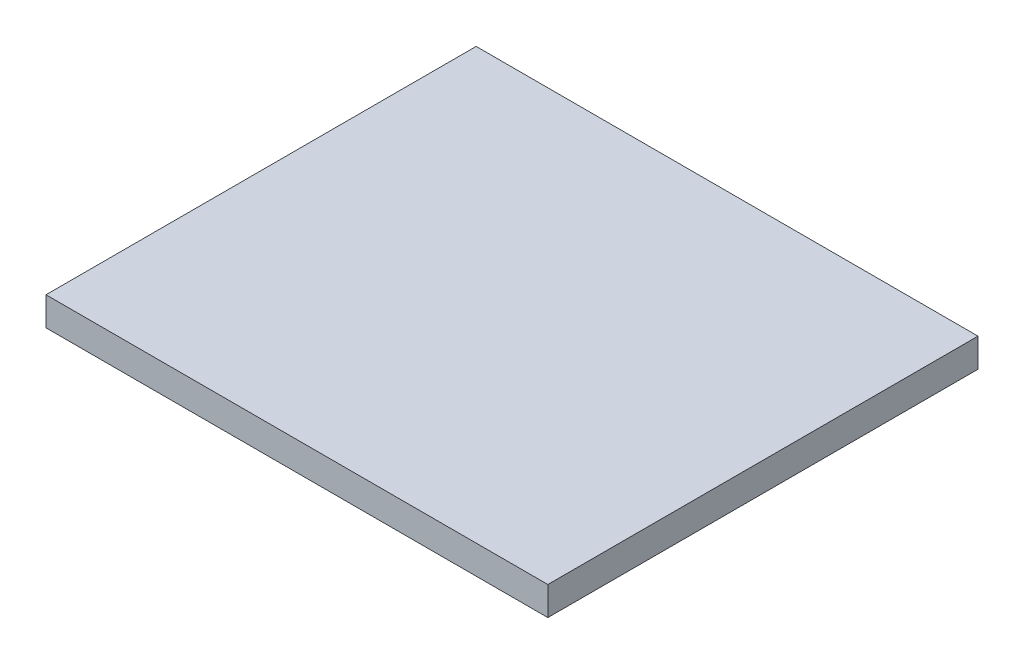
from build123d import *

# Parameters (mm, degrees)
SKETCH1_W           = 175
SKETCH1_H           = 150
BOSS_EXTRUDE2_DEPTH = 10


with BuildPart() as part:
    # Sketch1 → Boss-Extrude2 (new body)
    with BuildSketch(Plane(origin=(0, 0, 0), x_dir=(1, 0, 0), z_dir=(0, 1, 0))):
        with Locations((87.5, 75)):
            Rectangle(SKETCH1_W, SKETCH1_H)
    extrude(amount=BOSS_EXTRUDE2_DEPTH)


solid = part.part
